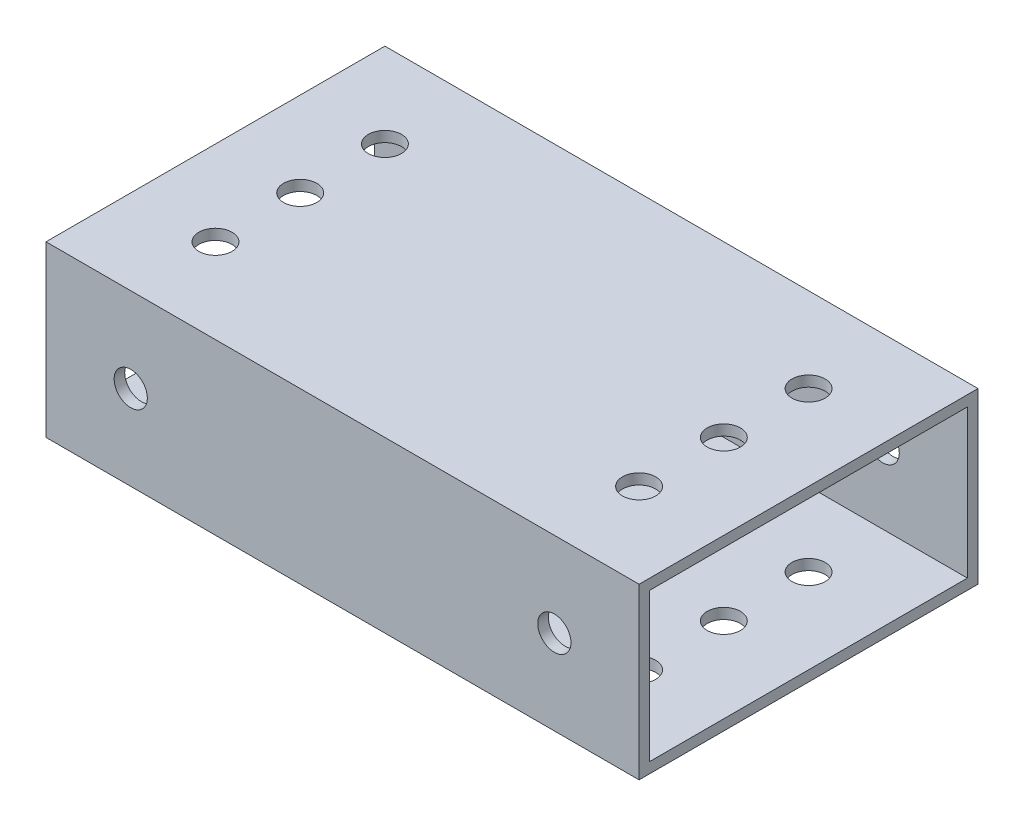
from build123d import *

# Parameters (mm, degrees)
SKETCH1_W           = 50.8
SKETCH1_H           = 25.4
BOSS_EXTRUDE1_DEPTH = 44.45
SHELL1_T            = -1.5875
SKETCH2_R           = 2.4892
CUT_EXTRUDE1_DEPTH  = 26.4
SKETCH3_R           = 2.4892
CUT_EXTRUDE2_DEPTH  = 51.8


with BuildPart() as part:
    # Sketch1 → Boss-Extrude1 (new body, symmetric)
    with BuildSketch(Plane(origin=(0, 0, 0), x_dir=(0, 0, -1), z_dir=(1, 0, 0))):
        with Locations((25.4, 12.7)):
            Rectangle(SKETCH1_W, SKETCH1_H)
    extrude(amount=BOSS_EXTRUDE1_DEPTH, both=True)

    # Shell1
    shell1_openings = [part.faces().sort_by_distance(p)[0] for p in [
        (44.45, 12.7, -25.4),
        (-44.45, 12.7, -25.4),
    ]]
    offset(amount=SHELL1_T, openings=shell1_openings, kind=Kind.INTERSECTION)

    # Sketch2 → Cut-Extrude1 (cut, through all)
    with BuildSketch(Plane(origin=(0, 25.4, 0), x_dir=(1, 0, 0), z_dir=(0, 1, 0))):
        with Locations((-31.75, 25.4)):
            Circle(SKETCH2_R)
        with Locations((-31.75, 12.7)):
            Circle(SKETCH2_R)
        with Locations((-31.75, 38.1)):
            Circle(SKETCH2_R)
    cut_extrude1 = extrude(amount=-CUT_EXTRUDE1_DEPTH, mode=Mode.SUBTRACT)

    # Sketch3 → Cut-Extrude2 (cut, through all)
    with BuildSketch(Plane.XY):
        with Locations((-31.75, 12.7)):
            Circle(SKETCH3_R)
    cut_extrude2 = extrude(amount=-CUT_EXTRUDE2_DEPTH, mode=Mode.SUBTRACT)

    # Mirror1: Cut-Extrude1, Cut-Extrude2 across plane
    add(cut_extrude1.mirror(Plane(origin=(0, 0, 0), x_dir=(0, 0, 1), z_dir=(1, 0, 0))), mode=Mode.SUBTRACT)
    add(cut_extrude2.mirror(Plane(origin=(0, 0, 0), x_dir=(0, 0, 1), z_dir=(1, 0, 0))), mode=Mode.SUBTRACT)


solid = part.part
